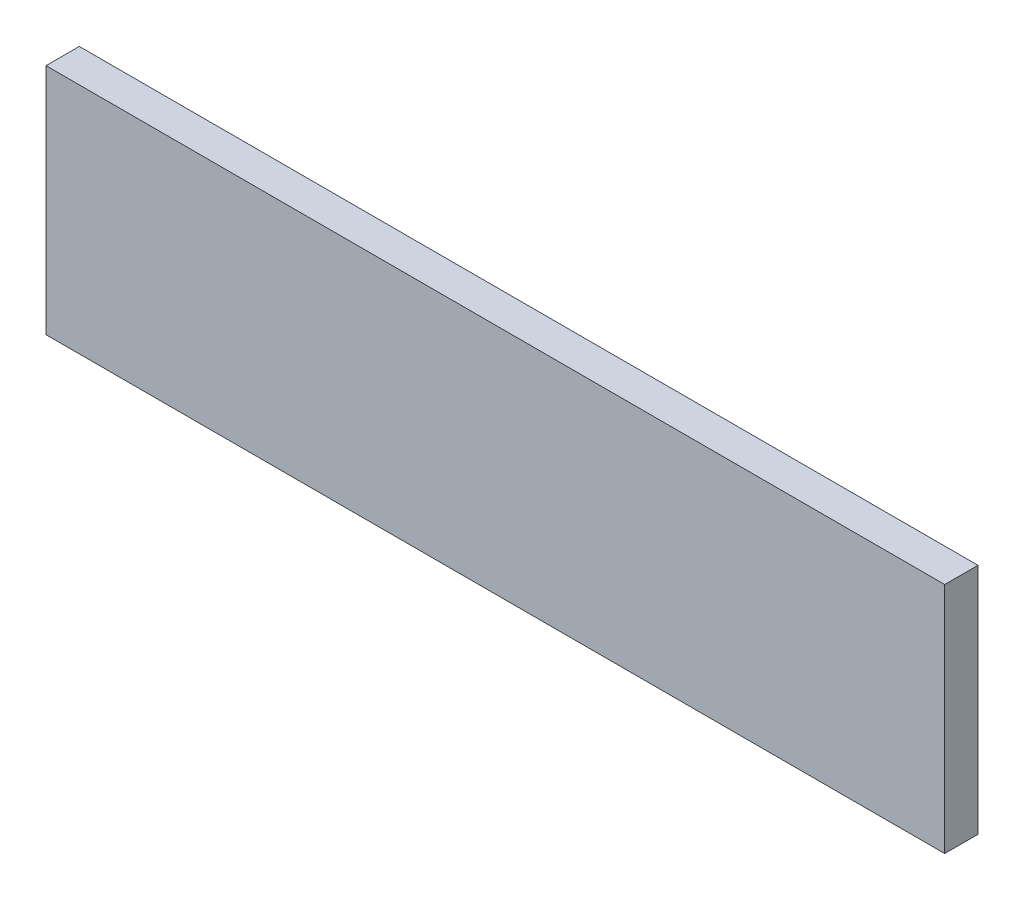
from build123d import *

# Parameters (mm, degrees)
SKETCH2_W           = 500
SKETCH2_H           = 50
BOSS_EXTRUDE1_DEPTH = 10
CUT_EXTRUDE1_REACH  = 12
SKETCH3_W           = 200
SKETCH3_H           = 60
SKETCH3_W_2         = 30
SKETCH3_H_2         = 50
SKETCH4_W           = 270
SKETCH4_H           = 10
BOSS_EXTRUDE2_DEPTH = 20


with BuildPart() as part:
    # Sketch2 → Boss-Extrude1 (new body)
    with BuildSketch(Plane.XY):
        with Locations((250, 25)):
            Rectangle(SKETCH2_W, SKETCH2_H)
    extrude(amount=BOSS_EXTRUDE1_DEPTH)

    # Sketch3 → Cut-Extrude1 (cut, up to next)
    with BuildSketch(Plane(origin=(0, 0, 0), x_dir=(-1, 0, 0), z_dir=(0, 0, -1)), mode=Mode.PRIVATE) as cut_extrude1_sk1:
        with Locations((-100, 30)):
            Rectangle(SKETCH3_W, SKETCH3_H)
    cut_extrude1_tool1 = extrude(cut_extrude1_sk1.sketch, amount=-CUT_EXTRUDE1_REACH, mode=Mode.PRIVATE) & part.part
    add(cut_extrude1_tool1.solids().sort_by_distance((100, 30, 0))[0], mode=Mode.SUBTRACT)
    # Sketch3 → Cut-Extrude1 (cut, up to next)
    with BuildSketch(Plane(origin=(0, 0, 0), x_dir=(-1, 0, 0), z_dir=(0, 0, -1)), mode=Mode.PRIVATE) as cut_extrude1_sk2:
        with Locations((-485, 25)):
            Rectangle(SKETCH3_W_2, SKETCH3_H_2)
    cut_extrude1_tool2 = extrude(cut_extrude1_sk2.sketch, amount=-CUT_EXTRUDE1_REACH, mode=Mode.PRIVATE) & part.part
    add(cut_extrude1_tool2.solids().sort_by_distance((485, 25, 0))[0], mode=Mode.SUBTRACT)

    # Sketch4 → Boss-Extrude2 (add)
    with BuildSketch(Plane(origin=(0, 50, 0), x_dir=(1, 0, 0), z_dir=(0, 1, 0))):
        with Locations((335, -5)):
            Rectangle(SKETCH4_W, SKETCH4_H)
    extrude(amount=BOSS_EXTRUDE2_DEPTH)


solid = part.part
